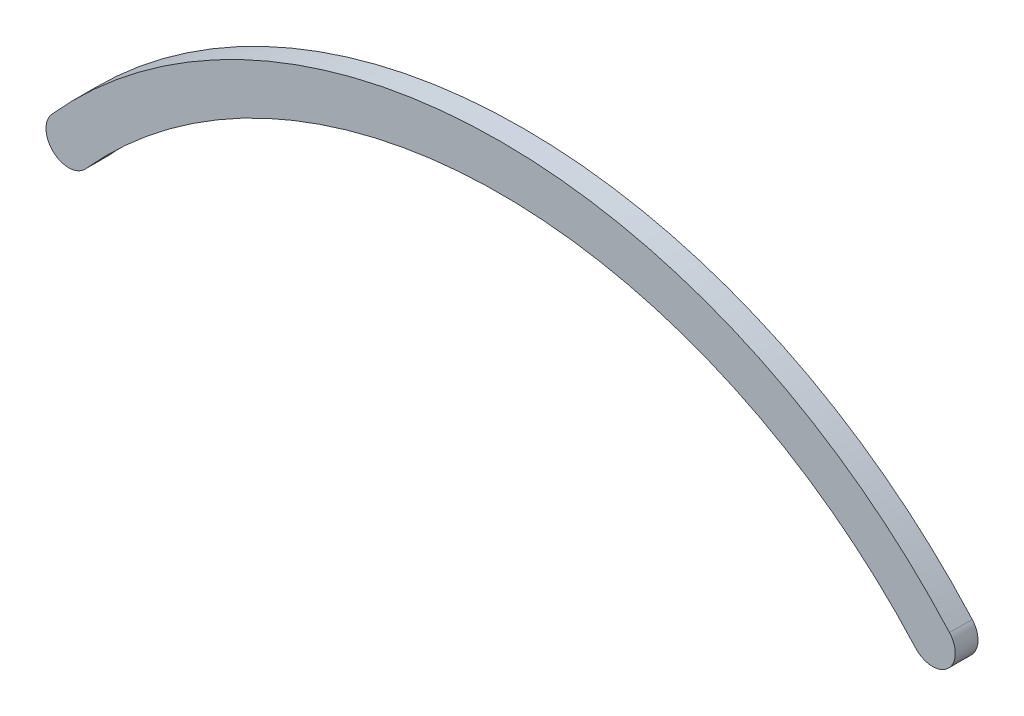
from build123d import *

# Parameters (mm, degrees)
SALIENTE_EXTRUIR1_DEPTH = 6.35


with BuildPart() as part:
    # Croquis1 → Saliente-Extruir1 (new body)
    with BuildSketch(Plane.XY):
        with BuildLine():
            ThreePointArc((-125.385033765, 4.231070225), (-124.880216294, -4.735796671), (-115.913440577, -4.229362225))
            ThreePointArc((-115.913440577, -4.229362225), (0, 47.667045852), (115.913440577, -4.229362225))
            ThreePointArc((115.913440577, -4.229362225), (124.880216294, -4.735796671), (125.385033765, 4.231070225))
            ThreePointArc((125.385033765, 4.231070225), (0, 60.340930176), (-125.385033765, 4.231070225))
        make_face()
    extrude(amount=SALIENTE_EXTRUIR1_DEPTH)


solid = part.part
